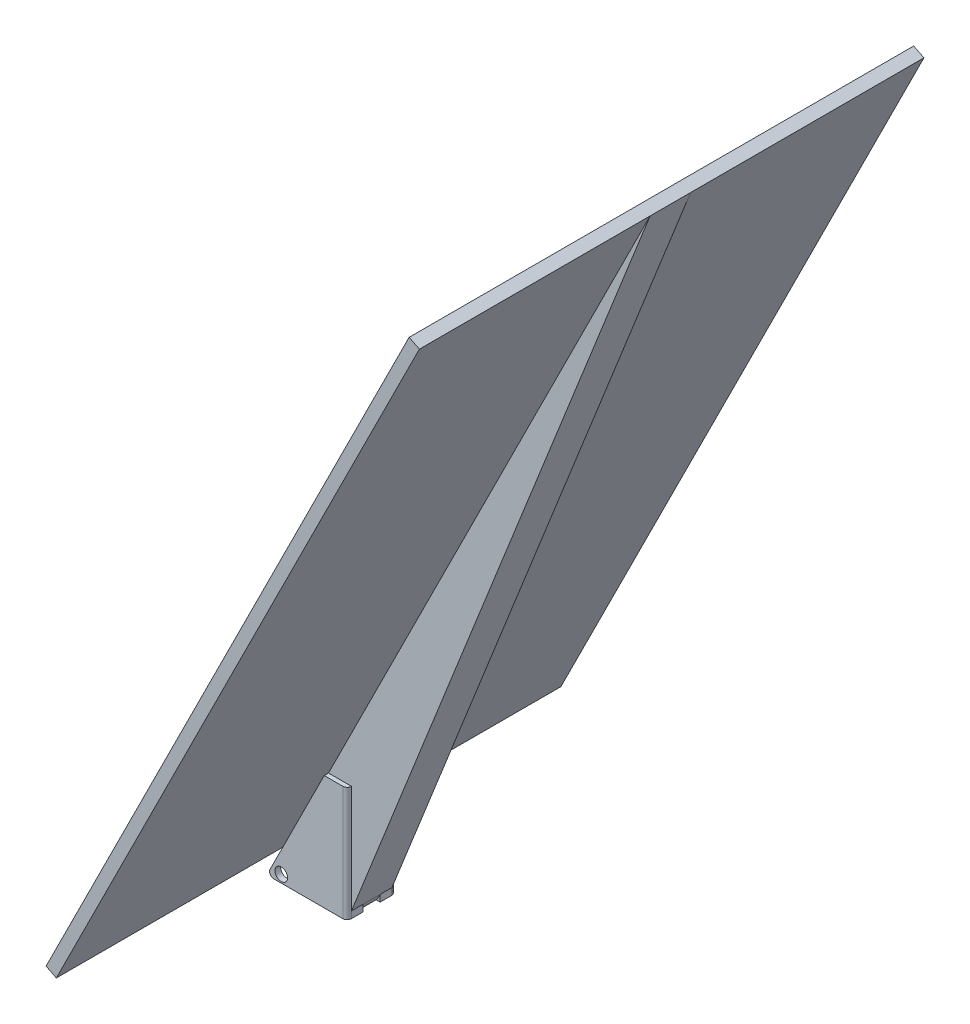
from build123d import *

# Parameters (mm, degrees)
BOSS_EXTRUDE1_DEPTH = 26.9875
SKETCH2_W           = 41.275
SKETCH2_H           = 20.6375
CUT_EXTRUDE1_DEPTH  = 64.5
SKETCH3_R           = 3.49885
CUT_EXTRUDE2_DEPTH  = 27.9875
FILLET1_R           = 2.38
FILLET2_R           = 2.38
SKETCH5_R           = 3.96875
CUT_EXTRUDE3_DEPTH  = 43.979079107
CUT_EXTRUDE4_DEPTH  = 43.979079107
SKETCH7_W           = 279.4
SKETCH7_H           = 449.58
BOSS_EXTRUDE2_DEPTH = 6.35
SKETCH11_W          = 22.404322508
SKETCH11_H          = 449.427276574
BOSS_EXTRUDE3_DEPTH = 38.1
CUT_EXTRUDE6_DEPTH  = 152.6075


with BuildPart() as part:
    # Sketch1 → Boss-Extrude1 (new body)
    with BuildSketch(Plane.XY):
        Polygon((-3.175, 19.685), (-34.925, -43.815), (9.525, -43.815), (9.525, 19.685), align=None)
    extrude(amount=BOSS_EXTRUDE1_DEPTH)

    # Sketch2 → Cut-Extrude1 (cut, through all)
    with BuildSketch(Plane(origin=(0, 19.685, 0), x_dir=(1, 0, 0), z_dir=(0, 1, 0))):
        with Locations((-14.2875, -13.49375)):
            Rectangle(SKETCH2_W, SKETCH2_H)
    extrude(amount=-CUT_EXTRUDE1_DEPTH, mode=Mode.SUBTRACT)

    # Sketch3 → Cut-Extrude2 (cut, through all)
    with BuildSketch(Plane.XY.offset(26.9875)):
        with Locations((-26.965492708, -39.543722561)):
            Circle(SKETCH3_R)
    extrude(amount=-CUT_EXTRUDE2_DEPTH, mode=Mode.SUBTRACT)

    # Fillet1
    fillet1_edges = [part.edges().sort_by_distance(p)[0] for p in [
        (9.525, -12.065, 26.9875),
        (9.525, -12.065, 0),
    ]]
    fillet(fillet1_edges, radius=FILLET1_R)

    # Fillet2
    fillet2_edges = [part.edges().sort_by_distance(p)[0] for p in [
        (-34.925, -43.815, 1.5875),
        (-34.925, -43.815, 25.4),
    ]]
    fillet(fillet2_edges, radius=FILLET2_R)

    # Sketch5 → Cut-Extrude3 (cut, through all)
    with BuildSketch(Plane(origin=(9.525, 0, 0), x_dir=(0, 0, -1), z_dir=(1, 0, 0))):
        with Locations((-12.488615689, 8.5725)):
            Circle(SKETCH5_R)
    extrude(amount=-CUT_EXTRUDE3_DEPTH, mode=Mode.SUBTRACT)

    # Sketch6 → Cut-Extrude4 (cut, through all)
    with BuildSketch(Plane(origin=(9.525, 0, 0), x_dir=(0, 0, -1), z_dir=(1, 0, 0))):
        with BuildLine():
            Line((-8.73125, -43.815), (-18.25625, -43.815))
            Line((-18.25625, -43.815), (-18.25625, -32.7025))
            ThreePointArc((-18.25625, -32.7025), (-13.49375, -27.94), (-8.73125, -32.7025))
            Line((-8.73125, -32.7025), (-8.73125, -43.815))
        make_face()
    extrude(amount=-CUT_EXTRUDE4_DEPTH, mode=Mode.SUBTRACT)

    # Sketch7 → Boss-Extrude2 (add)
    with BuildSketch(Plane(origin=(-10.414, 5.207, 0), x_dir=(0, 0, 1), z_dir=(-0.894427191, 0.447213595, 0))):
        with Locations((12.7, 189.707658697)):
            Rectangle(SKETCH7_W, SKETCH7_H)
    extrude(amount=BOSS_EXTRUDE2_DEPTH)

    # Sketch11 → Boss-Extrude3 (add)
    with BuildSketch(Plane(origin=(-10.414, 5.207, 0), x_dir=(0, 0, -1), z_dir=(0.894427191, -0.447213595, 0))):
        with Locations((-13.405338746, 189.78402041)):
            Rectangle(SKETCH11_W, SKETCH11_H)
    extrude(amount=BOSS_EXTRUDE3_DEPTH)

    # Sketch13 → Cut-Extrude6 (cut, through all)
    with BuildSketch(Plane.XY.offset(24.6075)):
        Polygon((174.954988272, 375.944976544), (9.525, -40.109189943), (209.032664249, 358.906138556), align=None)
    extrude(amount=-CUT_EXTRUDE6_DEPTH, mode=Mode.SUBTRACT)


solid = part.part
